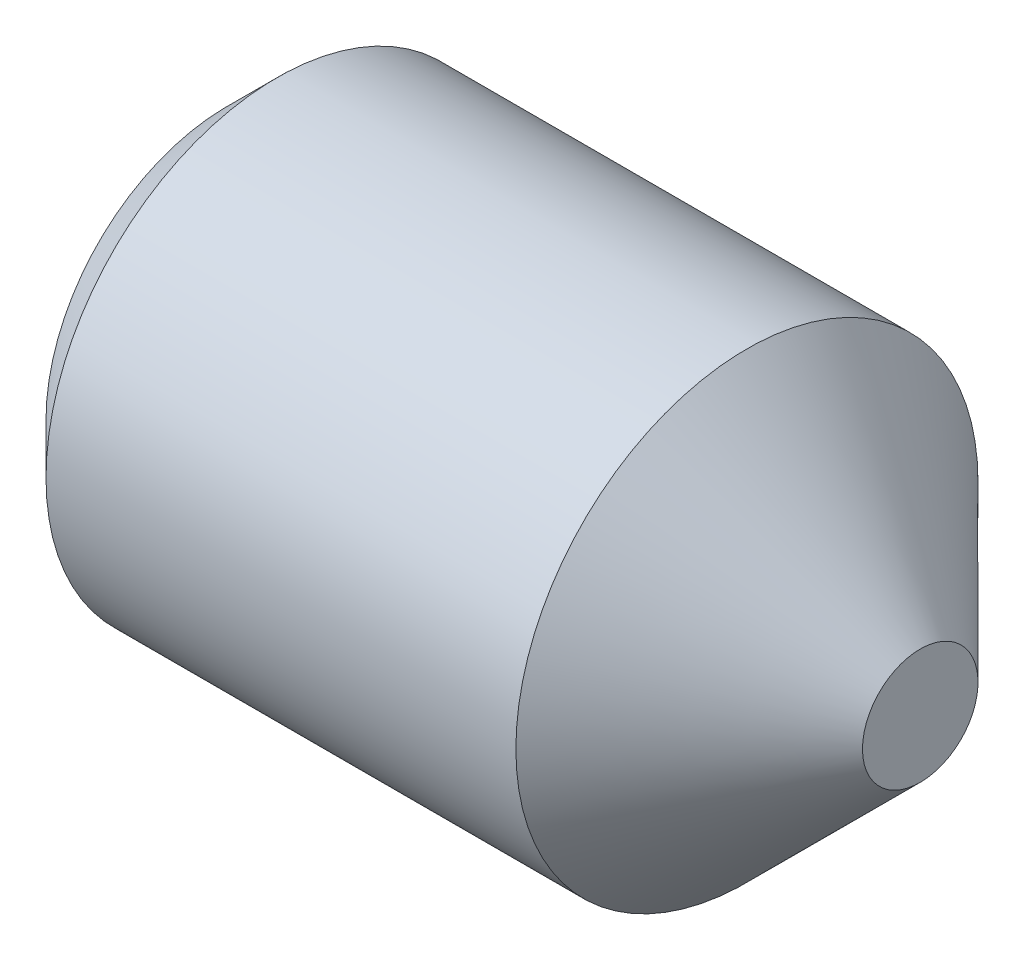
from build123d import *

# Parameters (mm, degrees)
HEXAGONSOCKET_DEPTH = 0.8


with BuildPart() as part:
    # Sketch1 → Base (revolve)
    with BuildSketch(Plane.XY):
        Polygon((0, 0), (3, 0), (3, 0.25), (2.25, 1), (0.2165, 1), (0, 0.7835), align=None)
    revolve(axis=Axis((-14.774129749, 0, 0), (1, 0, 0)))

    # Sketch2 → HexagonSocket (cut)
    with BuildSketch(Plane(origin=(0, 0.220293087, -0.139195271), x_dir=(0, 0, 1), z_dir=(-1, 0, 0))):
        Polygon((0.658810514, -0.220293087), (0.399002893, 0.229706913), (-0.12061235, 0.229706913), (-0.380419971, -0.220293087), (-0.12061235, -0.670293087), (0.399002893, -0.670293087), align=None)
    extrude(amount=-HEXAGONSOCKET_DEPTH, mode=Mode.SUBTRACT)

    # Sketch3 → Cut-Revolve (revolve, cut)
    with BuildSketch(Plane.XY):
        Polygon((0.8, 0.45), (1.059807621, 0), (0.8, 0), align=None)
    revolve(axis=Axis((0.8, 0, 0), (-1, 0, 0)), mode=Mode.SUBTRACT)


solid = part.part
